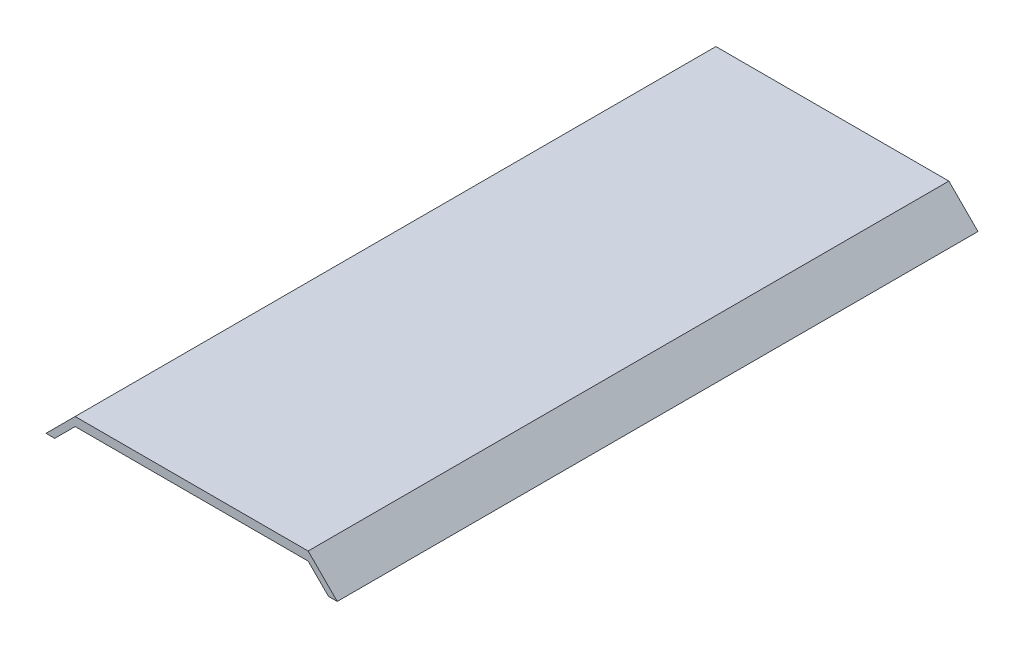
from build123d import *

# Parameters (mm, degrees)
SALIENTE_EXTRUIR1_DEPTH = 220


with BuildPart() as part:
    # Croquis1 → Saliente-Extruir1 (new body)
    with BuildSketch(Plane.XY):
        Polygon((-47, 0), (-50, 0), (-40, 10), (40, 10), (50, 0), (47, 0), (40, 7), (-40, 7), align=None)
    extrude(amount=SALIENTE_EXTRUIR1_DEPTH)


solid = part.part
